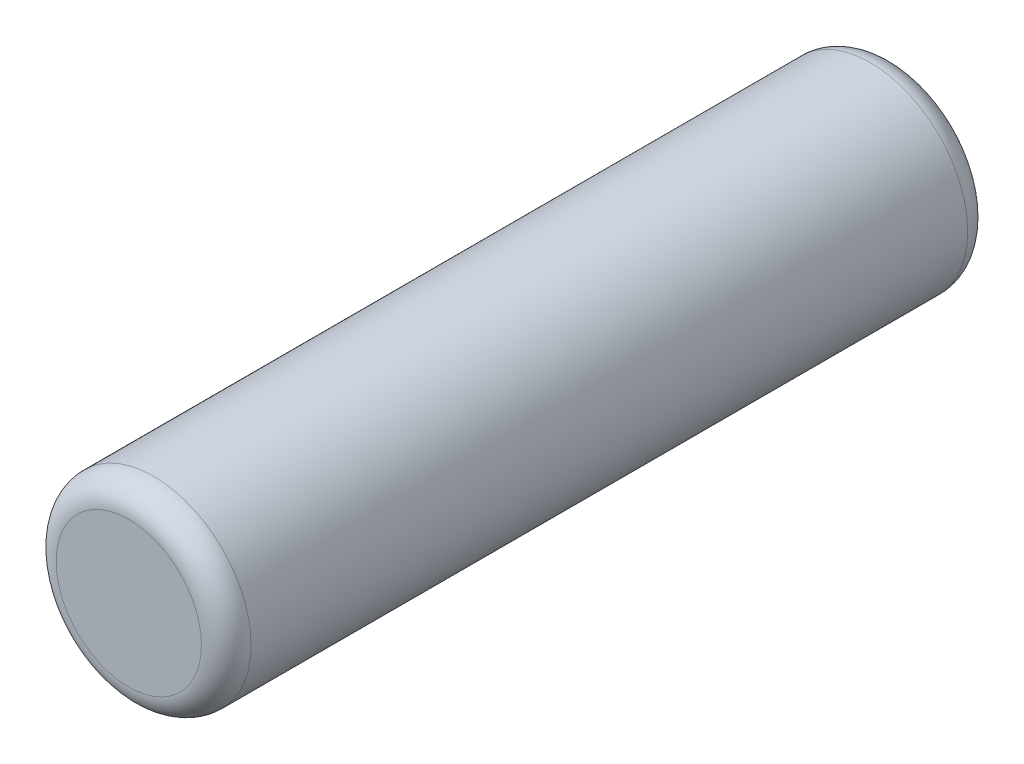
from build123d import *

# Parameters (mm, degrees)
SKETCH1_R          = 1.9939
BASE_EXTRUDE_DEPTH = 7.8359
FILLET1_R          = 0.508


with BuildPart() as part:
    # Sketch1 → Base-Extrude (new body, symmetric)
    with BuildSketch(Plane.XY):
        Circle(SKETCH1_R)
    extrude(amount=BASE_EXTRUDE_DEPTH, both=True)

    # Fillet1
    fillet1_edges = [part.edges().sort_by_distance(p)[0] for p in [
        (-1.9939, 0, -7.8359),
        (-1.9939, 0, 7.8359),
    ]]
    fillet(fillet1_edges, radius=FILLET1_R)


solid = part.part
